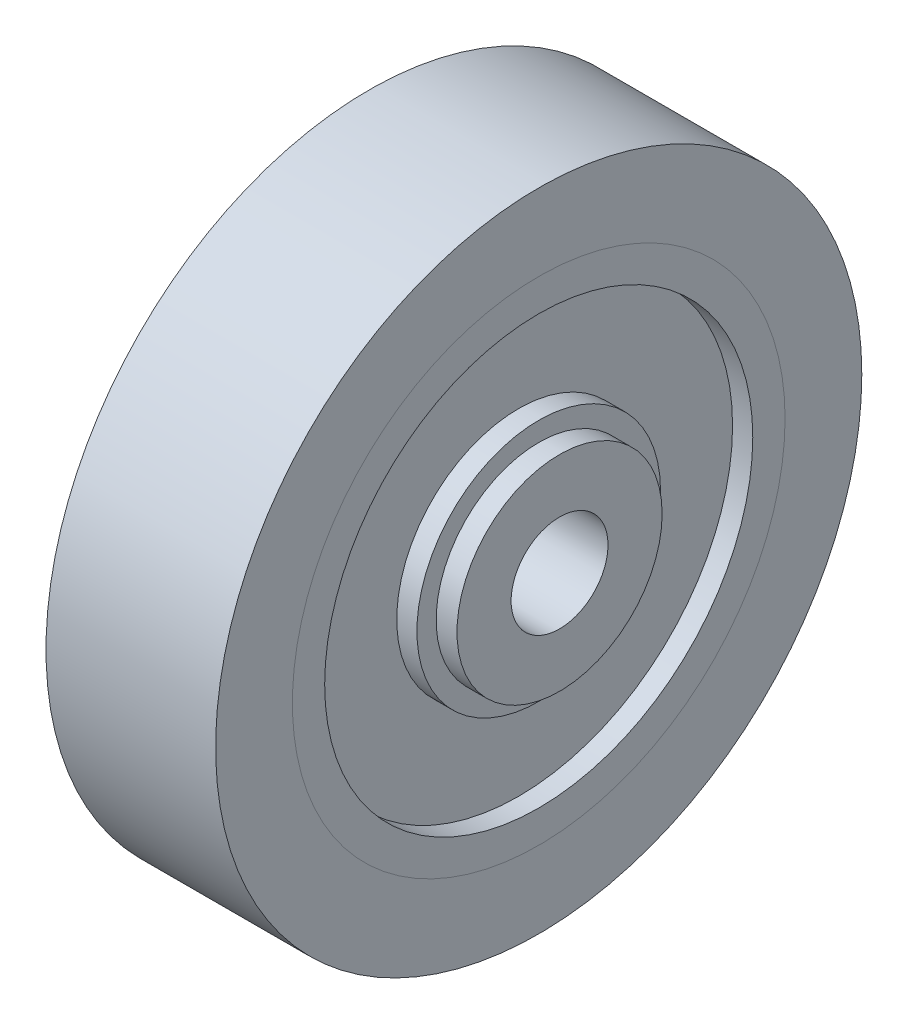
from build123d import *

# Parameters (mm, degrees)
SKETCH1_R                = 20
SKETCH1_R_2              = 15.25
BOSS_EXTRUDE1_DEPTH      = 10.5
SKETCH2_R                = 15.25
SKETCH2_R_2              = 13.25
BOSS_EXTRUDE2_DEPTH      = 10.5
SKETCH3_R                = 13.25
BOSS_EXTRUDE3_DEPTH      = 4
BOSS_EXTRUDE3_DEPTH_BACK = 4
SKETCH4_R                = 7.625
SKETCH4_R_2              = 3
BOSS_EXTRUDE4_DEPTH      = 1.25
SKETCH5_R                = 3
BOSS_EXTRUDE5_DEPTH      = 8
SKETCH6_R                = 5.94
SKETCH6_R_2              = 3
BOSS_EXTRUDE6_DEPTH      = 1.25
SKETCH7_R                = 6.35
SKETCH7_R_2              = 3
BOSS_EXTRUDE7_DEPTH      = 1.29
SKETCH8_R                = 1.5
CUT_EXTRUDE1_DEPTH       = 6.35
SKETCH9_R                = 7.54
SKETCH9_R_2              = 5.94
BOSS_EXTRUDE8_DEPTH      = 1.25


with BuildPart() as part:
    # Sketch1 → Boss-Extrude1 (new body)
    with BuildSketch(Plane(origin=(0, 0, 0), x_dir=(0, 0, -1), z_dir=(1, 0, 0))):
        Circle(SKETCH1_R)
        Circle(SKETCH1_R_2, mode=Mode.SUBTRACT)
    extrude(amount=BOSS_EXTRUDE1_DEPTH)


with BuildPart() as body_2:
    # Sketch2 → Boss-Extrude2 (new body)
    with BuildSketch(Plane(origin=(10.5, 0, 0), x_dir=(0, 0, -1), z_dir=(1, 0, 0))):
        Circle(SKETCH2_R)
        Circle(SKETCH2_R_2, mode=Mode.SUBTRACT)
    extrude(amount=-BOSS_EXTRUDE2_DEPTH)

    # Sketch3 → Boss-Extrude3 (add, two sides)
    with BuildSketch(Plane(origin=(5.25, 0, 0), x_dir=(0, 0, -1), z_dir=(1, 0, 0))) as boss_extrude3_sk:
        Circle(SKETCH3_R)
        Polygon((7.332348419, 0), (3.666174209, 6.35), (-3.666174209, 6.35), (-7.332348419, 0), (-3.666174209, -6.35), (3.666174209, -6.35), align=None, mode=Mode.SUBTRACT)
    extrude(amount=BOSS_EXTRUDE3_DEPTH)
    extrude(boss_extrude3_sk.sketch, amount=-BOSS_EXTRUDE3_DEPTH_BACK)


with BuildPart() as body_3:
    # Sketch4 → Boss-Extrude4 (new body)
    with BuildSketch(Plane.ZY.offset(-1.25)):
        Circle(SKETCH4_R)
        Circle(SKETCH4_R_2, mode=Mode.SUBTRACT)
    extrude(amount=BOSS_EXTRUDE4_DEPTH)

    # Sketch5 → Boss-Extrude5 (add)
    with BuildSketch(Plane(origin=(1.25, 0, 0), x_dir=(0, 0, -1), z_dir=(1, 0, 0))):
        Polygon((-7.332348419, 0), (-3.666174209, 6.35), (3.666174209, 6.35), (7.332348419, 0), (3.666174209, -6.35), (-3.666174209, -6.35), align=None)
        Circle(SKETCH5_R, mode=Mode.SUBTRACT)
    extrude(amount=BOSS_EXTRUDE5_DEPTH)

    # Sketch6 → Boss-Extrude6 (add)
    with BuildSketch(Plane(origin=(9.25, 0, 0), x_dir=(0, 0, -1), z_dir=(1, 0, 0))):
        Circle(SKETCH6_R)
        Circle(SKETCH6_R_2, mode=Mode.SUBTRACT)
    extrude(amount=BOSS_EXTRUDE6_DEPTH)

    # Sketch7 → Boss-Extrude7 (add)
    with BuildSketch(Plane(origin=(10.5, 0, 0), x_dir=(0, 0, -1), z_dir=(1, 0, 0))):
        Circle(SKETCH7_R)
        Circle(SKETCH7_R_2, mode=Mode.SUBTRACT)
    extrude(amount=BOSS_EXTRUDE7_DEPTH)

    # Sketch8 → Cut-Extrude1 (cut)
    with BuildSketch(Plane(origin=(0, 6.35, 0), x_dir=(1, 0, 0), z_dir=(0, 1, 0))):
        with Locations((5.25, 0)):
            Circle(SKETCH8_R)
    extrude(amount=-CUT_EXTRUDE1_DEPTH, mode=Mode.SUBTRACT)


with BuildPart() as body_4:
    # Sketch9 → Boss-Extrude8 (new body)
    with BuildSketch(Plane(origin=(9.25, 0, 0), x_dir=(0, 0, -1), z_dir=(1, 0, 0))):
        Circle(SKETCH9_R)
        Circle(SKETCH9_R_2, mode=Mode.SUBTRACT)
    extrude(amount=BOSS_EXTRUDE8_DEPTH)


solid = Compound([part.part, body_2.part, body_3.part, body_4.part])
